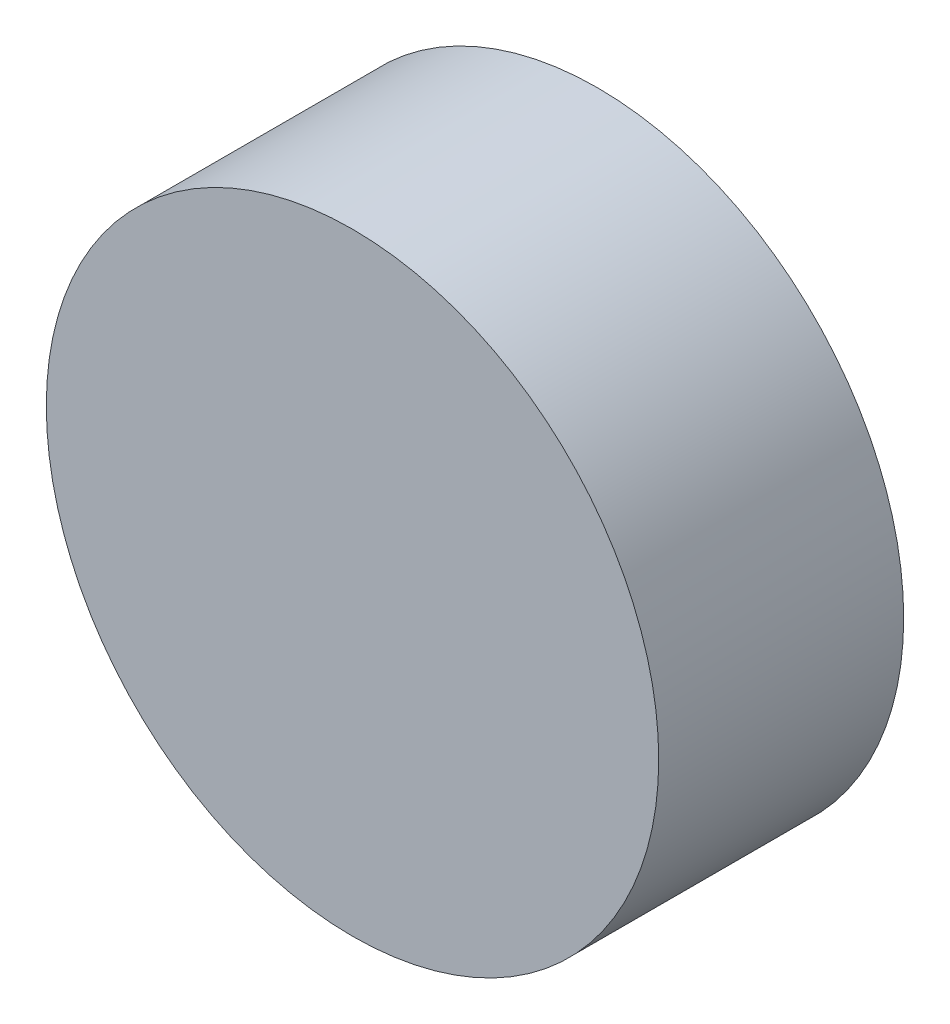
from build123d import *

# Parameters (mm, degrees)
SKETCH1_R           = 250
BOSS_EXTRUDE2_DEPTH = 200


with BuildPart() as part:
    # Sketch1 → Boss-Extrude2 (new body)
    with BuildSketch(Plane.XY):
        Circle(SKETCH1_R)
    extrude(amount=BOSS_EXTRUDE2_DEPTH)


solid = part.part
